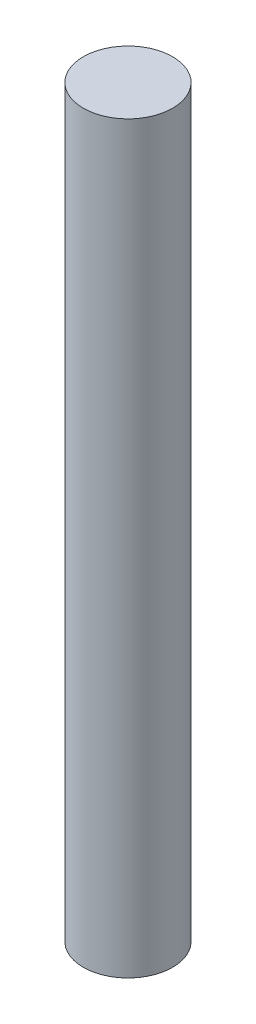
from build123d import *

# Parameters (mm, degrees)
SKETCH2_R           = 1.8
BOSS_EXTRUDE1_DEPTH = 30


with BuildPart() as part:
    # Sketch2 → Boss-Extrude1 (new body)
    with BuildSketch(Plane(origin=(0, 0, 0), x_dir=(1, 0, 0), z_dir=(0, 1, 0))):
        Circle(SKETCH2_R)
    extrude(amount=BOSS_EXTRUDE1_DEPTH)


solid = part.part
